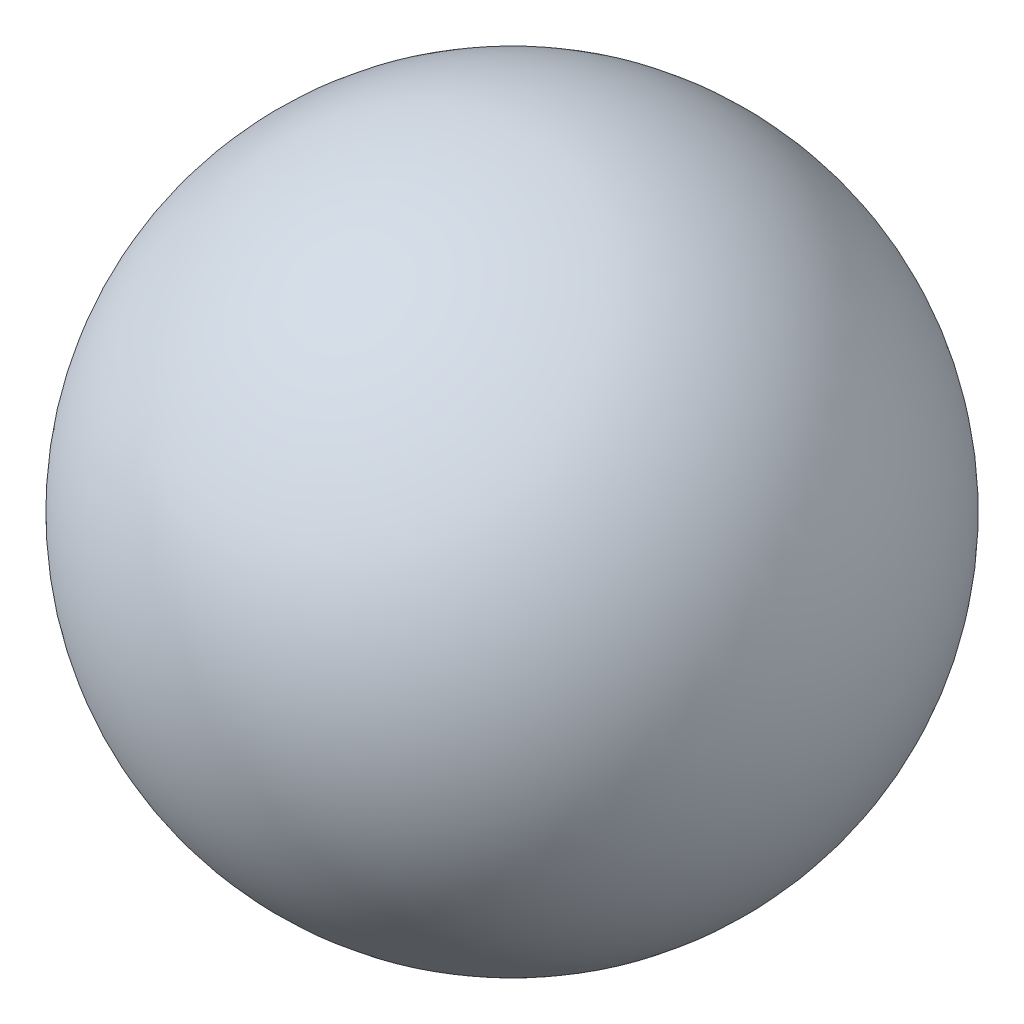
from build123d import *


with BuildPart() as part:
    # Sketch1 → Revolve1 (revolve)
    with BuildSketch(Plane.XY):
        with BuildLine():
            Line((0, 0.25), (0, -0.25))
            ThreePointArc((0, -0.25), (-0.25, 0), (0, 0.25))
        make_face()
    revolve(axis=Axis((0, 0.25, 0), (0, -1, 0)))


solid = part.part
